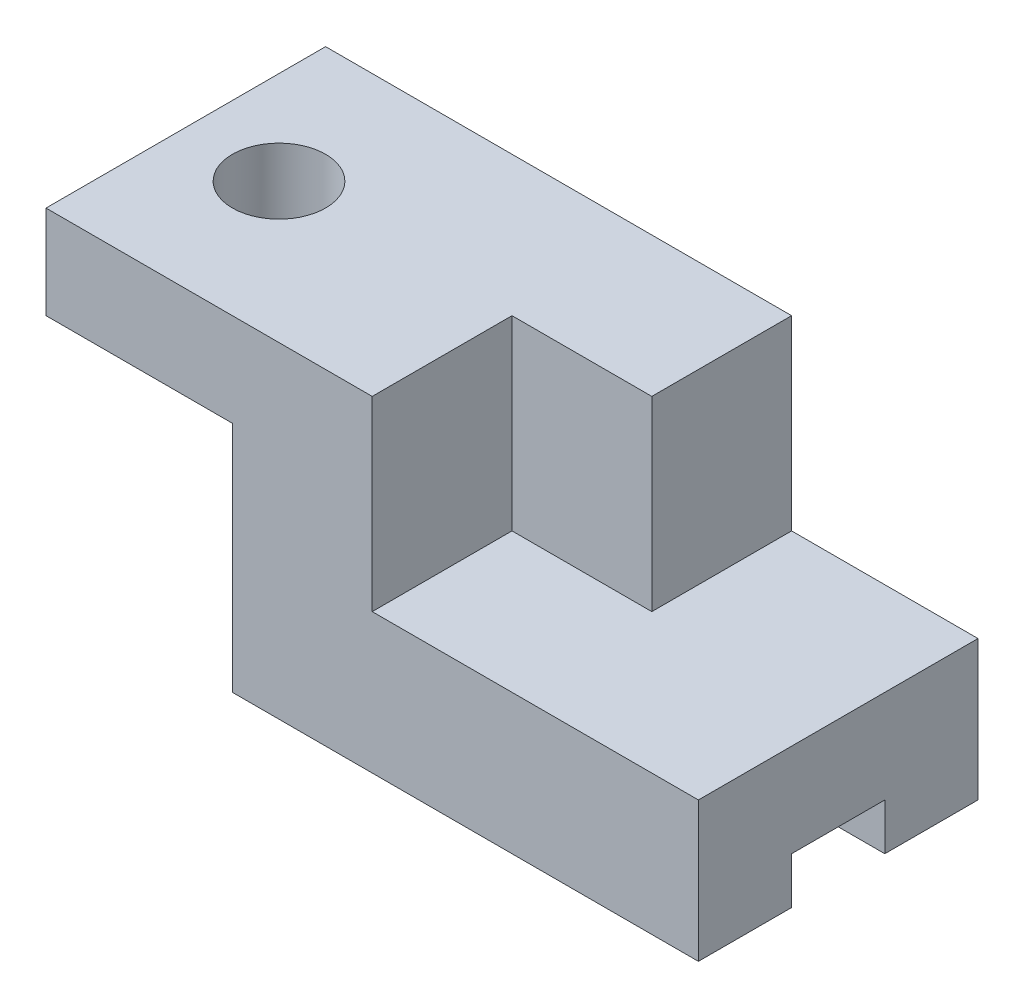
from build123d import *

# Parameters (mm, degrees)
SKETCH1_W           = 70
SKETCH1_H           = 30
BOSS_EXTRUDE1_DEPTH = 35
CUT_EXTRUDE1_DEPTH  = 20
SKETCH3_W           = 20
SKETCH3_H           = 25
CUT_EXTRUDE2_DEPTH  = 31
SKETCH4_R           = 5
CUT_EXTRUDE3_DEPTH  = 36
SKETCH5_W           = 10
SKETCH5_H           = 5
CUT_EXTRUDE4_DEPTH  = 71


with BuildPart() as part:
    # Sketch1 → Boss-Extrude1 (new body)
    with BuildSketch(Plane(origin=(0, 0, 0), x_dir=(1, 0, 0), z_dir=(0, 1, 0))):
        with Locations((35, 15)):
            Rectangle(SKETCH1_W, SKETCH1_H)
    extrude(amount=BOSS_EXTRUDE1_DEPTH)

    # Sketch2 → Cut-Extrude1 (cut)
    with BuildSketch(Plane(origin=(0, 35, 0), x_dir=(1, 0, 0), z_dir=(0, 1, 0))):
        Polygon((70, 30), (50, 30), (50, 15), (35, 15), (35, 0), (70, 0), align=None)
    extrude(amount=-CUT_EXTRUDE1_DEPTH, mode=Mode.SUBTRACT)

    # Sketch3 → Cut-Extrude2 (cut, through all)
    with BuildSketch(Plane.XY):
        with Locations((10, 12.5)):
            Rectangle(SKETCH3_W, SKETCH3_H)
    extrude(amount=-CUT_EXTRUDE2_DEPTH, mode=Mode.SUBTRACT)

    # Sketch4 → Cut-Extrude3 (cut, through all)
    with BuildSketch(Plane(origin=(0, 35, 0), x_dir=(1, 0, 0), z_dir=(0, 1, 0))):
        with Locations((10, 15)):
            Circle(SKETCH4_R)
    extrude(amount=-CUT_EXTRUDE3_DEPTH, mode=Mode.SUBTRACT)

    # Sketch5 → Cut-Extrude4 (cut, through all)
    with BuildSketch(Plane(origin=(70, 0, 0), x_dir=(0, 0, -1), z_dir=(1, 0, 0))):
        with Locations((15, 2.5)):
            Rectangle(SKETCH5_W, SKETCH5_H)
    extrude(amount=-CUT_EXTRUDE4_DEPTH, mode=Mode.SUBTRACT)


solid = part.part
